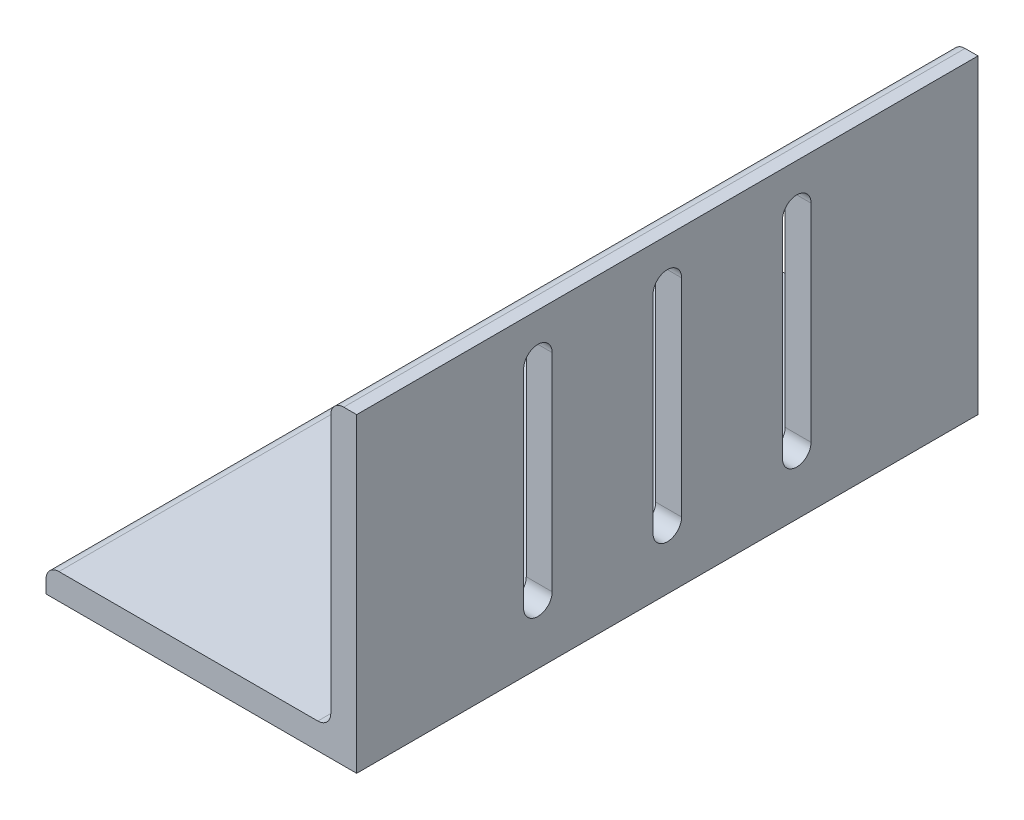
from build123d import *

# Parameters (mm, degrees)
BOSS_EXTRUDE1_DEPTH = 76.2
CUT_EXTRUDE1_DEPTH  = 10
SKETCH4_R           = 3.5
CUT_EXTRUDE2_DEPTH  = 10


with BuildPart() as part:
    # Sketch2 → Boss-Extrude1 (new body, symmetric)
    with BuildSketch(Plane.XY):
        with BuildLine():
            Line((-38.1, 0), (38.1, 0))
            Line((38.1, 0), (38.1, 76.2))
            Line((38.1, 76.2), (34.925, 76.2))
            ThreePointArc((34.925, 76.2), (32.67993597, 75.27006403), (31.75, 73.025))
            Line((31.75, 73.025), (31.75, 9.525))
            ThreePointArc((31.75, 9.525), (30.82006403, 7.27993597), (28.575, 6.35))
            Line((28.575, 6.35), (-34.925, 6.35))
            ThreePointArc((-34.925, 6.35), (-37.17006403, 5.42006403), (-38.1, 3.175))
            Line((-38.1, 3.175), (-38.1, 0))
        make_face()
    extrude(amount=BOSS_EXTRUDE1_DEPTH, both=True)

    # Sketch3 → Cut-Extrude1 (cut)
    with BuildSketch(Plane(origin=(38.1, 0, 0), x_dir=(0, 0, -1), z_dir=(1, 0, 0))):
        with BuildLine():
            Line((-28.25, 65.4), (-28.25, 14.6))
            ThreePointArc((-28.25, 14.6), (-31.75, 11.1), (-35.25, 14.6))
            Line((-35.25, 14.6), (-35.25, 65.4))
            ThreePointArc((-35.25, 65.4), (-31.75, 68.9), (-28.25, 65.4))
        make_face()
        with BuildLine():
            Line((28.25, 65.4), (28.25, 14.6))
            ThreePointArc((28.25, 14.6), (31.75, 11.1), (35.25, 14.6))
            Line((35.25, 14.6), (35.25, 65.4))
            ThreePointArc((35.25, 65.4), (31.75, 68.9), (28.25, 65.4))
        make_face()
        with BuildLine():
            Line((3.5, 65.4), (3.5, 14.6))
            ThreePointArc((3.5, 14.6), (0, 11.1), (-3.5, 14.6))
            Line((-3.5, 14.6), (-3.5, 65.4))
            ThreePointArc((-3.5, 65.4), (0, 68.9), (3.5, 65.4))
        make_face()
    extrude(amount=-CUT_EXTRUDE1_DEPTH, mode=Mode.SUBTRACT)

    # Sketch4 → Cut-Extrude2 (cut)
    with BuildSketch(Plane.XZ):
        with Locations((-12.35, 25.4)):
            Circle(SKETCH4_R)
        with Locations((-12.35, -25.4)):
            Circle(SKETCH4_R)
        with Locations((-12.35, 0)):
            Circle(SKETCH4_R)
    extrude(amount=-CUT_EXTRUDE2_DEPTH, mode=Mode.SUBTRACT)


solid = part.part
